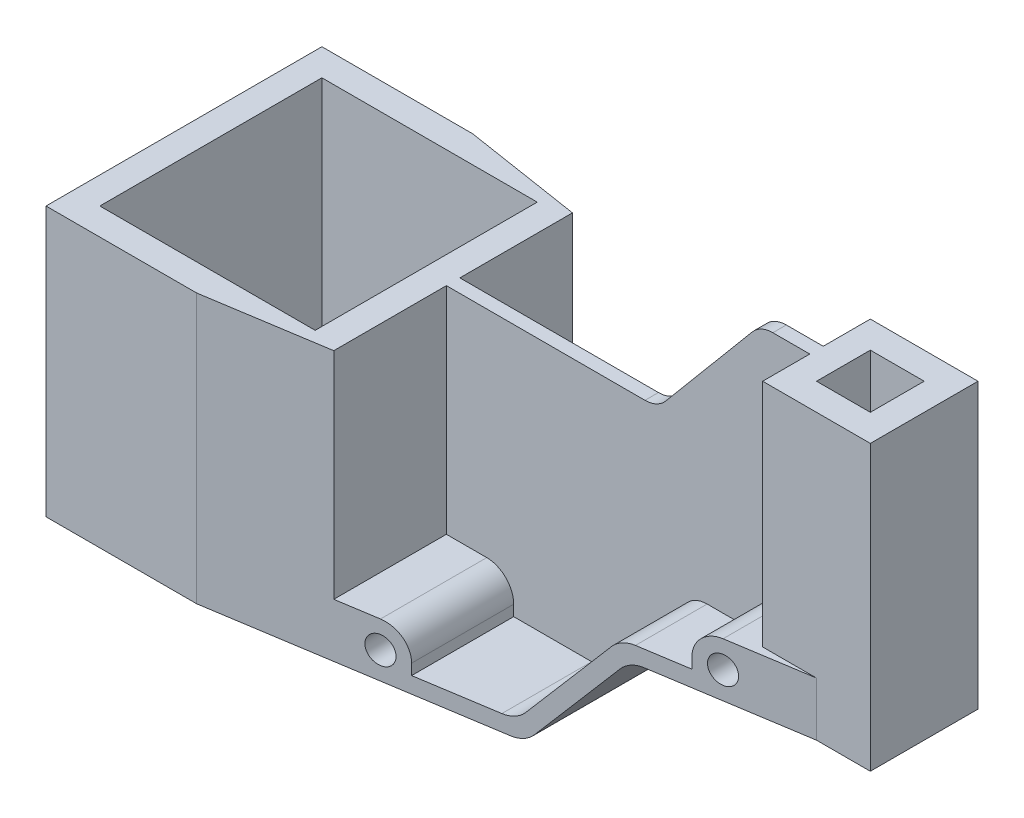
from build123d import *

# Parameters (mm, degrees)
SKETCH1_W           = 275
SKETCH1_H           = 145.5
BOSS_EXTRUDE1_DEPTH = 102.5
SKETCH3_W           = 115
SKETCH3_H           = 45.5
SKETCH3_W_2         = 80
SKETCH3_H_2         = 40
CUT_EXTRUDE1_DEPTH  = 102.5
SKETCH4_W           = 80
SKETCH4_H           = 82.5
CUT_EXTRUDE3_DEPTH  = 100
CUT_EXTRUDE4_DEPTH  = 105.5
SKETCH7_W           = 20
SKETCH7_H           = 31.25
SKETCH7_H_2         = 31.588652779
CUT_EXTRUDE5_DEPTH  = 105.5
CUT_EXTRUDE7_DEPTH  = 85.5
SKETCH10_W          = 100
SKETCH10_H          = 48.75
CUT_EXTRUDE8_DEPTH  = 14
SKETCH11_W          = 100
SKETCH11_H          = 48.75
CUT_EXTRUDE9_DEPTH  = 14
SKETCH12_W          = 10
SKETCH12_H          = 48.75
CUT_EXTRUDE10_DEPTH = 26
SKETCH13_W          = 10
SKETCH13_H          = 48.75
CUT_EXTRUDE12_DEPTH = 26
SKETCH14_W          = 15
SKETCH14_H          = 48.75
CUT_EXTRUDE13_DEPTH = 80
CUT_EXTRUDE14_DEPTH = 102.5
CUT_EXTRUDE15_DEPTH = 48.75
CUT_EXTRUDE16_DEPTH = 48.75
CUT_EXTRUDE17_DEPTH = 5
CUT_EXTRUDE18_DEPTH = 105
SKETCH24_R          = 5
CUT_EXTRUDE19_DEPTH = 105
CUT_EXTRUDE20_DEPTH = 105
FILLET1_R           = 10
FILLET2_R           = 10
FILLET3_R           = 10
FILLET4_R           = 10
FILLET5_R           = 10
FILLET6_R           = 10
FILLET7_R           = 10
FILLET8_R           = 10
FILLET9_R           = 10
FILLET10_R          = 10
FILLET11_R          = 10
FILLET12_R          = 10


with BuildPart() as part:
    # Sketch1 → Boss-Extrude1 (new body)
    with BuildSketch(Plane.XY):
        with Locations((93.302092116, 48.653058441)):
            Rectangle(SKETCH1_W, SKETCH1_H)
    extrude(amount=BOSS_EXTRUDE1_DEPTH)

    # Sketch3 → Cut-Extrude1 (cut)
    with BuildSketch(Plane.XY.offset(102.5)):
        with Locations((13.302092116, 98.653058441)):
            Rectangle(SKETCH3_W, SKETCH3_H)
        with Locations((190.802092116, -4.096941559)):
            Rectangle(SKETCH3_W_2, SKETCH3_H_2)
    extrude(amount=-CUT_EXTRUDE1_DEPTH, mode=Mode.SUBTRACT)

    # Sketch4 → Cut-Extrude3 (cut)
    with BuildSketch(Plane(origin=(0, 75.903058441, 0), x_dir=(1, 0, 0), z_dir=(0, 1, 0))):
        with Locations((5.802092116, -51.25)):
            Rectangle(SKETCH4_W, SKETCH4_H)
    extrude(amount=-CUT_EXTRUDE3_DEPTH, mode=Mode.SUBTRACT)

    # Sketch6 → Cut-Extrude4 (cut)
    with BuildSketch(Plane(origin=(0, 121.403058441, 0), x_dir=(1, 0, 0), z_dir=(0, 1, 0))):
        Polygon((200.803509438, -51.25), (200.803509438, -41.25), (220.802092116, -41.25), (220.802092116, -51.25), (220.802092116, -61.25), (200.803509438, -61.25), align=None)
    extrude(amount=-CUT_EXTRUDE4_DEPTH, mode=Mode.SUBTRACT)

    # Sketch7 → Cut-Extrude5 (cut)
    with BuildSketch(Plane(origin=(0, 121.403058441, 0), x_dir=(1, 0, 0), z_dir=(0, 1, 0))):
        with Locations((220.802092116, -15.625)):
            Rectangle(SKETCH7_W, SKETCH7_H)
        with Locations((220.802092116, -87.04432639)):
            Rectangle(SKETCH7_W, SKETCH7_H_2)
    extrude(amount=-CUT_EXTRUDE5_DEPTH, mode=Mode.SUBTRACT)

    # Sketch8 → Cut-Extrude7 (cut)
    with BuildSketch(Plane(origin=(0, 121.403058441, 0), x_dir=(1, 0, 0), z_dir=(0, 1, 0))):
        Polygon((190.802092116, -31.25), (190.802092116, -48.75), (70.802092116, -48.75), (70.802092116, 0), (210.802092116, 0), (210.802092116, -31.25), align=None)
        Polygon((190.802092116, -71.25), (190.802092116, -53.75), (70.802092116, -53.75), (70.802092116, -102.5), (210.802092116, -102.5), (210.802092116, -71.25), align=None)
    extrude(amount=-CUT_EXTRUDE7_DEPTH, mode=Mode.SUBTRACT)

    # Sketch10 → Cut-Extrude8 (cut)
    with BuildSketch(Plane(origin=(0, 35.903058441, 0), x_dir=(1, 0, 0), z_dir=(0, 1, 0))):
        with Locations((120.802092116, -78.125)):
            Rectangle(SKETCH10_W, SKETCH10_H)
    extrude(amount=-CUT_EXTRUDE8_DEPTH, mode=Mode.SUBTRACT)

    # Sketch11 → Cut-Extrude9 (cut)
    with BuildSketch(Plane(origin=(0, 35.903058441, 0), x_dir=(1, 0, 0), z_dir=(0, 1, 0))):
        with Locations((120.802092116, -24.375)):
            Rectangle(SKETCH11_W, SKETCH11_H)
    extrude(amount=-CUT_EXTRUDE9_DEPTH, mode=Mode.SUBTRACT)

    # Sketch12 → Cut-Extrude10 (cut)
    with BuildSketch(Plane(origin=(0, 21.903058441, 0), x_dir=(1, 0, 0), z_dir=(0, 1, 0))):
        with Locations((75.802092116, -78.125)):
            Rectangle(SKETCH12_W, SKETCH12_H)
    extrude(amount=-CUT_EXTRUDE10_DEPTH, mode=Mode.SUBTRACT)

    # Sketch13 → Cut-Extrude12 (cut)
    with BuildSketch(Plane(origin=(0, 21.903058441, 0), x_dir=(1, 0, 0), z_dir=(0, 1, 0))):
        with Locations((75.802092116, -24.375)):
            Rectangle(SKETCH13_W, SKETCH13_H)
    extrude(amount=-CUT_EXTRUDE12_DEPTH, mode=Mode.SUBTRACT)

    # Sketch14 → Cut-Extrude13 (cut)
    with BuildSketch(Plane(origin=(0, 75.903058441, 0), x_dir=(1, 0, 0), z_dir=(0, 1, 0))):
        with Locations((63.302092116, -78.125)):
            Rectangle(SKETCH14_W, SKETCH14_H)
        with Locations((63.302092116, -24.375)):
            Rectangle(SKETCH14_W, SKETCH14_H)
    extrude(amount=-CUT_EXTRUDE13_DEPTH, mode=Mode.SUBTRACT)

    # Sketch16 → Cut-Extrude14 (cut)
    with BuildSketch(Plane.XY.offset(102.5)):
        Polygon((150.802092116, 15.903058441), (117.238106869, -24.096941559), (150.802092116, -24.096941559), align=None)
    extrude(amount=-CUT_EXTRUDE14_DEPTH, mode=Mode.SUBTRACT)

    # Sketch17 → Cut-Extrude15 (cut)
    with BuildSketch(Plane.XY.offset(102.5)):
        Polygon((80.802092116, -4.096941559), (80.802092116, -18.096941559), (114.44026092, -18.096941559), (148.004246167, 21.903058441), (80.802092116, 21.903058441), align=None)
    extrude(amount=-CUT_EXTRUDE15_DEPTH, mode=Mode.SUBTRACT)

    # Sketch18 → Cut-Extrude16 (cut)
    with BuildSketch(Plane(origin=(0, 0, 0), x_dir=(-1, 0, 0), z_dir=(0, 0, -1))):
        Polygon((-80.802092116, -4.096941559), (-80.802092116, -18.096941559), (-114.44026092, -18.096941559), (-148.004246167, 21.903058441), (-80.802092116, 21.903058441), align=None)
    extrude(amount=-CUT_EXTRUDE16_DEPTH, mode=Mode.SUBTRACT)

    # Sketch19 → Cut-Extrude17 (cut)
    with BuildSketch(Plane.XY.offset(53.75)):
        Polygon((70.802092116, 75.903058441), (134.245946408, 75.903058441), (172.424979627, 121.403058441), (70.802092116, 121.403058441), align=None)
    extrude(amount=-CUT_EXTRUDE17_DEPTH, mode=Mode.SUBTRACT)

    # Sketch23 → Cut-Extrude18 (cut)
    with BuildSketch(Plane.XZ.offset(24.096941559)):
        Polygon((11.802092116, 102.5), (210.802092116, 71.25), (210.802092116, 102.5), align=None)
    extrude(amount=-CUT_EXTRUDE18_DEPTH, mode=Mode.SUBTRACT)

    # Sketch24 → Cut-Extrude19 (cut)
    with BuildSketch(Plane(origin=(0, 0, 0), x_dir=(-1, 0, 0), z_dir=(0, 0, -1))):
        with Locations((-180.802092116, 25.903058441)):
            Circle(SKETCH24_R)
        with Locations((-70.802092116, -14.096941559)):
            Circle(SKETCH24_R)
    extrude(amount=-CUT_EXTRUDE19_DEPTH, mode=Mode.SUBTRACT)

    # Sketch25 → Cut-Extrude20 (cut)
    with BuildSketch(Plane.XZ.offset(24.096941559)):
        Polygon((11.802092116, 0), (210.802092116, 0), (210.802092116, 31.25), align=None)
    extrude(amount=-CUT_EXTRUDE20_DEPTH, mode=Mode.SUBTRACT)

    # Fillet1
    fillet1_edges = [part.edges().sort_by_distance(p)[0] for p in [
        (80.802092116, -4.096941559, 72.707286432),
    ]]
    fillet(fillet1_edges, radius=FILLET1_R)

    # Fillet2
    fillet2_edges = [part.edges().sort_by_distance(p)[0] for p in [
        (148.004246167, 21.903058441, 67.430735392),
    ]]
    fillet(fillet2_edges, radius=FILLET2_R)

    # Fillet3
    fillet3_edges = [part.edges().sort_by_distance(p)[0] for p in [
        (170.802092116, 35.903058441, 65.640703518),
    ]]
    fillet(fillet3_edges, radius=FILLET3_R)

    # Fillet4
    fillet4_edges = [part.edges().sort_by_distance(p)[0] for p in [
        (80.802092116, -4.096941559, 29.792713568),
    ]]
    fillet(fillet4_edges, radius=FILLET4_R)

    # Fillet5
    fillet5_edges = [part.edges().sort_by_distance(p)[0] for p in [
        (148.004246167, 21.903058441, 35.069264608),
    ]]
    fillet(fillet5_edges, radius=FILLET5_R)

    # Fillet6
    fillet6_edges = [part.edges().sort_by_distance(p)[0] for p in [
        (170.802092116, 35.903058441, 36.859296482),
    ]]
    fillet(fillet6_edges, radius=FILLET6_R)

    # Fillet7
    fillet7_edges = [part.edges().sort_by_distance(p)[0] for p in [
        (114.44026092, -18.096941559, 32.433901445),
    ]]
    fillet(fillet7_edges, radius=FILLET7_R)

    # Fillet8
    fillet8_edges = [part.edges().sort_by_distance(p)[0] for p in [
        (114.44026092, -18.096941559, 70.066098555),
    ]]
    fillet(fillet8_edges, radius=FILLET8_R)

    # Fillet9
    fillet9_edges = [part.edges().sort_by_distance(p)[0] for p in [
        (134.245946408, 75.903058441, 51.25),
    ]]
    fillet(fillet9_edges, radius=FILLET9_R)

    # Fillet10
    fillet10_edges = [part.edges().sort_by_distance(p)[0] for p in [
        (172.424979627, 121.403058441, 51.25),
    ]]
    fillet(fillet10_edges, radius=FILLET10_R)

    # Fillet11
    fillet11_edges = [part.edges().sort_by_distance(p)[0] for p in [
        (150.802092116, 15.903058441, 51.25),
    ]]
    fillet(fillet11_edges, radius=FILLET11_R)

    # Fillet12
    fillet12_edges = [part.edges().sort_by_distance(p)[0] for p in [
        (117.238106869, -24.096941559, 51.25),
    ]]
    fillet(fillet12_edges, radius=FILLET12_R)


solid = part.part
